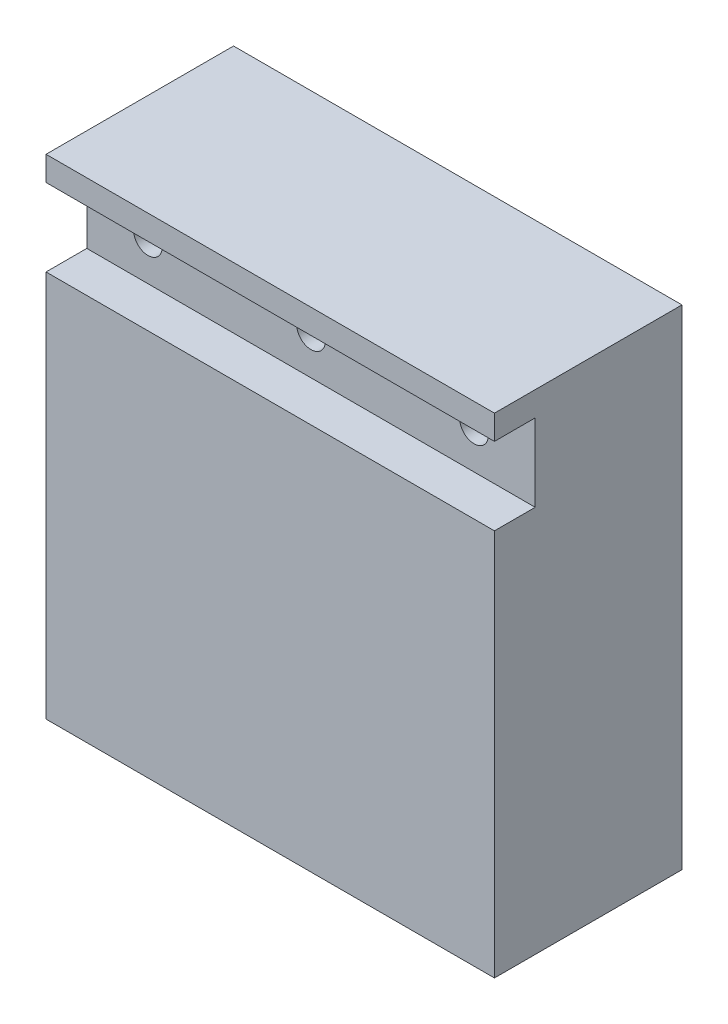
from build123d import *

# Parameters (mm, degrees)
SKETCH1_W           = 23
SKETCH1_H           = 60
BOSS_EXTRUDE1_DEPTH = 55
SKETCH2_W           = 55
SKETCH2_H           = 9.5
CUT_EXTRUDE1_DEPTH  = 5
SKETCH3_R           = 1.75
CUT_EXTRUDE2_DEPTH  = 3


with BuildPart() as part:
    # Sketch1 → Boss-Extrude1 (new body)
    with BuildSketch(Plane(origin=(0, 0, 0), x_dir=(0, 0, -1), z_dir=(1, 0, 0))):
        with Locations((11.5, 30)):
            Rectangle(SKETCH1_W, SKETCH1_H)
    extrude(amount=BOSS_EXTRUDE1_DEPTH)

    # Sketch2 → Cut-Extrude1 (cut)
    with BuildSketch(Plane.XY):
        with Locations((27.5, 52.25)):
            Rectangle(SKETCH2_W, SKETCH2_H)
    extrude(amount=-CUT_EXTRUDE1_DEPTH, mode=Mode.SUBTRACT)

    # Sketch3 → Cut-Extrude2 (cut)
    with BuildSketch(Plane.XY.offset(-5)):
        with Locations((7.5, 52.25)):
            Circle(SKETCH3_R)
        with Locations((27.5, 52.25)):
            Circle(SKETCH3_R)
        with Locations((47.5, 52.25)):
            Circle(SKETCH3_R)
    extrude(amount=-CUT_EXTRUDE2_DEPTH, mode=Mode.SUBTRACT)


solid = part.part
